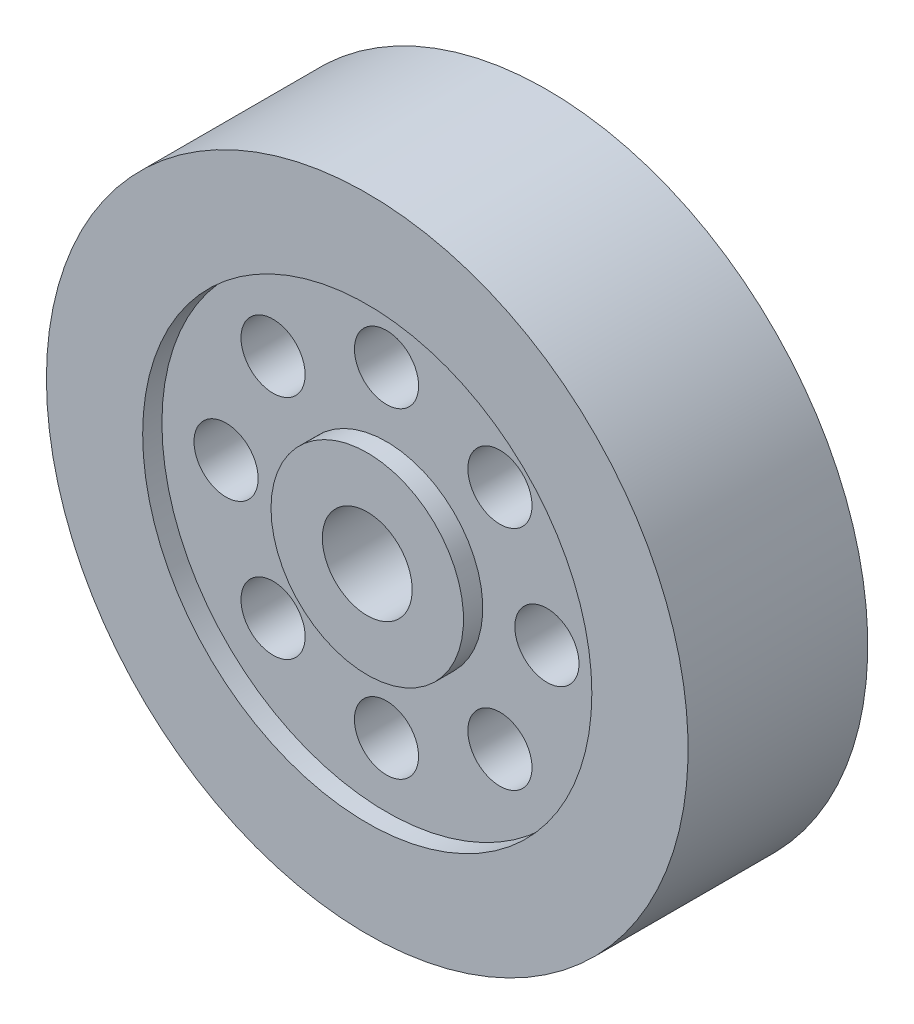
from build123d import *

# Parameters (mm, degrees)
SKETCH2_R          = 5
CUT_EXTRUDE1_DEPTH = 12
CIRPATTERN1_COUNT  = 8


with BuildPart() as part:
    # Sketch1 → Revolve1 (revolve)
    with BuildSketch(Plane(origin=(0, 0, 0), x_dir=(1, 0, 0), z_dir=(0, 1, 0))):
        Polygon((7, 0), (7, 14), (15, 14), (15, 11), (35, 11), (35, 14), (50, 14), (50, 0), align=None)
    revolve(axis=Axis((0, 0, -184.045185168), (0, 0, 1)))

    # Sketch2 → Cut-Extrude1 (cut, through all)
    with BuildSketch(Plane(origin=(0, 0, -11), x_dir=(-1, 0, 0), z_dir=(0, 0, -1))):
        with Locations((0, -25)):
            Circle(SKETCH2_R)
    cut_extrude1 = extrude(amount=-CUT_EXTRUDE1_DEPTH, mode=Mode.SUBTRACT)

    # CirPattern1: Cut-Extrude1 ×8 about axis
    cirpattern1_axis = Axis((0, 0, 0), (0, 0, 1))
    for i in range(1, CIRPATTERN1_COUNT):
        add(cut_extrude1.rotate(cirpattern1_axis, i * 360 / CIRPATTERN1_COUNT), mode=Mode.SUBTRACT)

    # Mirror1: part across plane


with BuildPart() as part_1:
    add(part.part)
    add(part.part.mirror(Plane.XY))


solid = part_1.part
